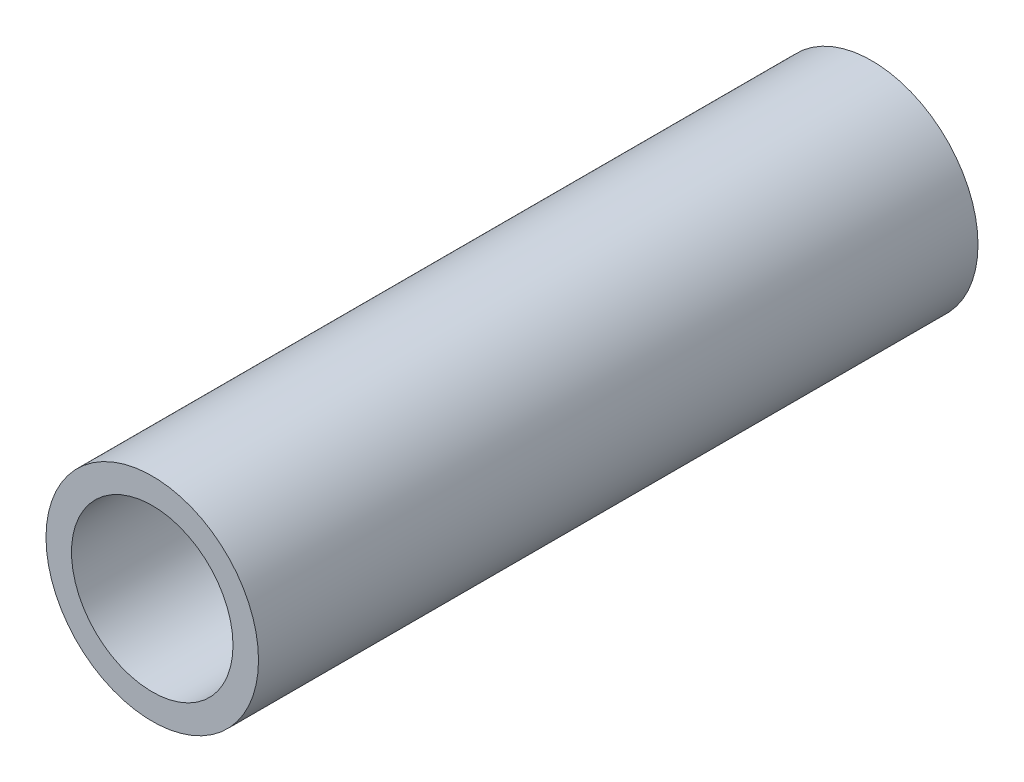
from build123d import *

# Parameters (mm, degrees)
SKETCH1_R           = 3.175
SKETCH1_R_2         = 2.413
BOSS_EXTRUDE1_DEPTH = 10.75


with BuildPart() as part:
    # Sketch1 → Boss-Extrude1 (new body, symmetric)
    with BuildSketch(Plane.XY):
        Circle(SKETCH1_R)
        Circle(SKETCH1_R_2, mode=Mode.SUBTRACT)
    extrude(amount=BOSS_EXTRUDE1_DEPTH, both=True)


solid = part.part
